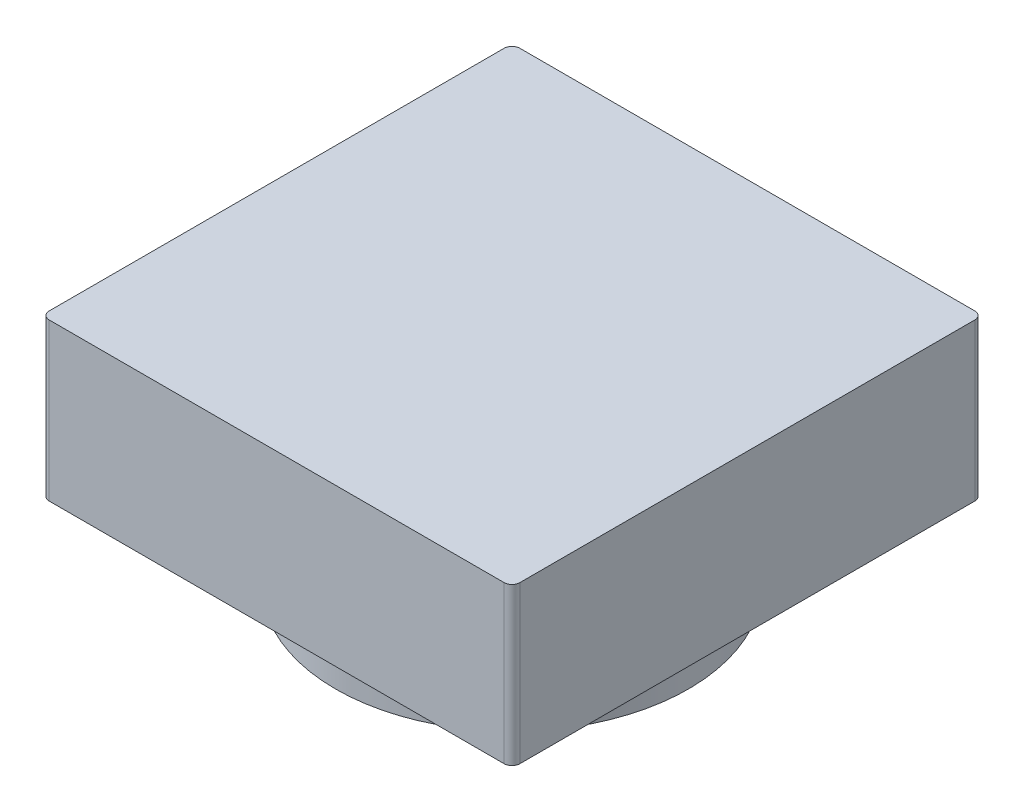
from build123d import *

# Parameters (mm, degrees)
SKETCH1_R           = 22.5
BOSS_EXTRUDE1_DEPTH = 10
BOSS_EXTRUDE2_DEPTH = 20
SKETCH3_R           = 16.5
CUT_EXTRUDE2_DEPTH  = 5


with BuildPart() as part:
    # Sketch1 → Boss-Extrude1 (new body)
    with BuildSketch(Plane(origin=(0, 0, 0), x_dir=(1, 0, 0), z_dir=(0, 1, 0))):
        Circle(SKETCH1_R)
    extrude(amount=BOSS_EXTRUDE1_DEPTH)

    # Sketch2 → Boss-Extrude2 (add)
    with BuildSketch(Plane(origin=(0, 10, 0), x_dir=(1, 0, 0), z_dir=(0, 1, 0))):
        with BuildLine():
            Line((-29, 30), (29, 30))
            ThreePointArc((29, 30), (29.707106781, 29.707106781), (30, 29))
            Line((30, 29), (30, -29))
            ThreePointArc((30, -29), (29.707106781, -29.707106781), (29, -30))
            Line((29, -30), (-29, -30))
            ThreePointArc((-29, -30), (-29.707106781, -29.707106781), (-30, -29))
            Line((-30, -29), (-30, 29))
            ThreePointArc((-30, 29), (-29.707106781, 29.707106781), (-29, 30))
        make_face()
    extrude(amount=BOSS_EXTRUDE2_DEPTH)

    # Sketch3 → Cut-Extrude2 (cut)
    with BuildSketch(Plane.XZ):
        with BuildLine():
            ThreePointArc((-14.551420086, 2.778571429), (0, 11.5), (14.551420086, 2.778571429))
            Line((14.551420086, 2.778571429), (4.83856504, 20.948467447))
            ThreePointArc((4.83856504, 20.948467447), (0, 21.5), (-4.83856504, 20.948467447))
            Line((-4.83856504, 20.948467447), (-14.551420086, 2.778571429))
        make_face()
        with Locations((0, -5)):
            Circle(SKETCH3_R)
    extrude(amount=-CUT_EXTRUDE2_DEPTH, mode=Mode.SUBTRACT)


solid = part.part
